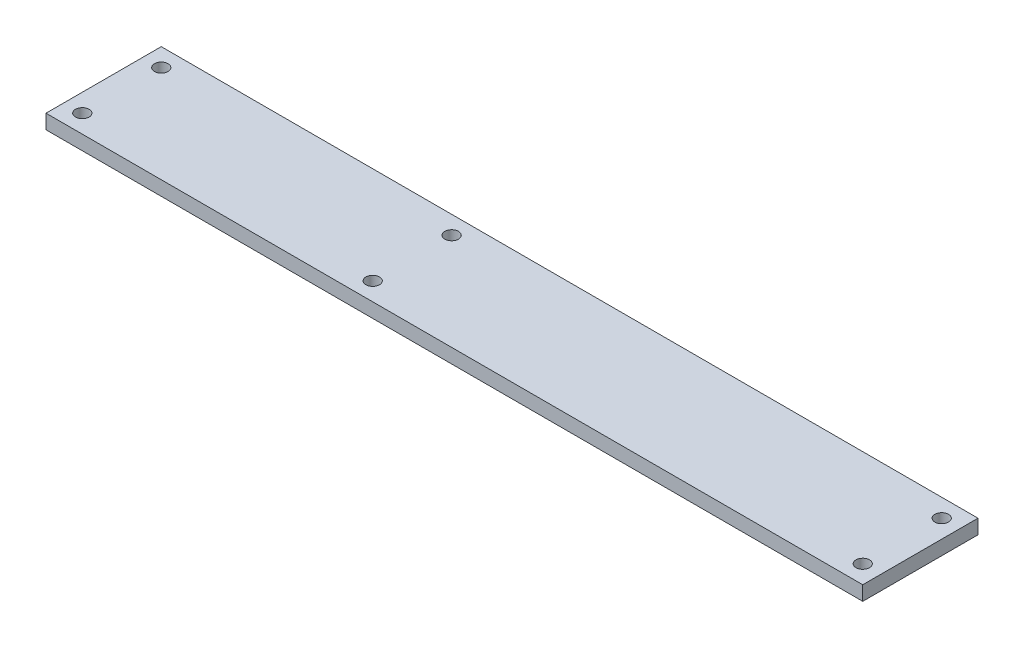
from build123d import *

# Parameters (mm, degrees)
CROQUIS1_W              = 180
CROQUIS1_H              = 25.4
CROQUIS1_R              = 1.5
SALIENTE_EXTRUIR1_DEPTH = 3.175


with BuildPart() as part:
    # Croquis1 → Saliente-Extruir1 (new body)
    with BuildSketch(Plane(origin=(0, 0, 0), x_dir=(1, 0, 0), z_dir=(0, 1, 0))):
        Rectangle(CROQUIS1_W, CROQUIS1_H)
        with Locations((-86, 8.7)):
            Circle(CROQUIS1_R, mode=Mode.SUBTRACT)
        with Locations((-86, -8.7)):
            Circle(CROQUIS1_R, mode=Mode.SUBTRACT)
        with Locations((86, -8.7)):
            Circle(CROQUIS1_R, mode=Mode.SUBTRACT)
        with Locations((86, 8.7)):
            Circle(CROQUIS1_R, mode=Mode.SUBTRACT)
        with Locations((-22, 8.7)):
            Circle(CROQUIS1_R, mode=Mode.SUBTRACT)
        with Locations((-22, -8.7)):
            Circle(CROQUIS1_R, mode=Mode.SUBTRACT)
    extrude(amount=SALIENTE_EXTRUIR1_DEPTH)


solid = part.part
